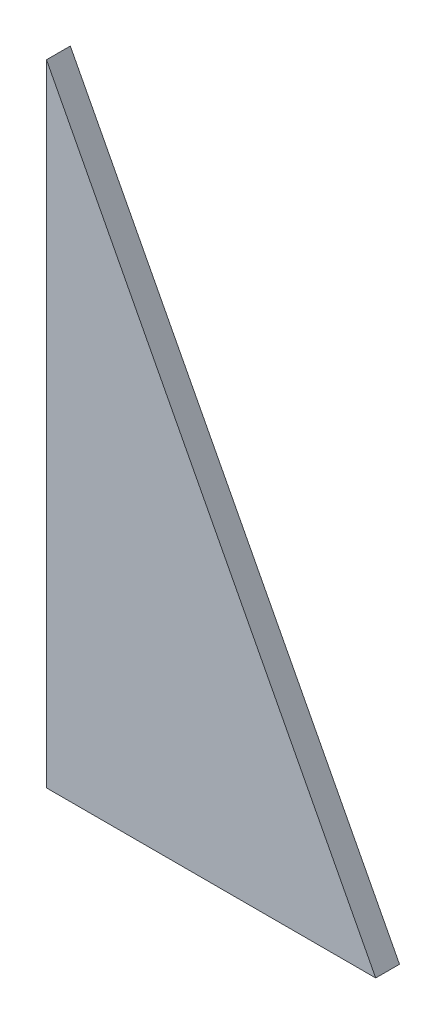
from build123d import *

# Parameters (mm, degrees)
AUFSATZ_LINEAR_AUSTRAGEN1_DEPTH = 18


with BuildPart() as part:
    # Skizze1 → Aufsatz-Linear austragen1 (new body)
    with BuildSketch(Plane.XY):
        Polygon((0, 477), (0, 0), (249, 0), align=None)
    extrude(amount=AUFSATZ_LINEAR_AUSTRAGEN1_DEPTH)


solid = part.part
